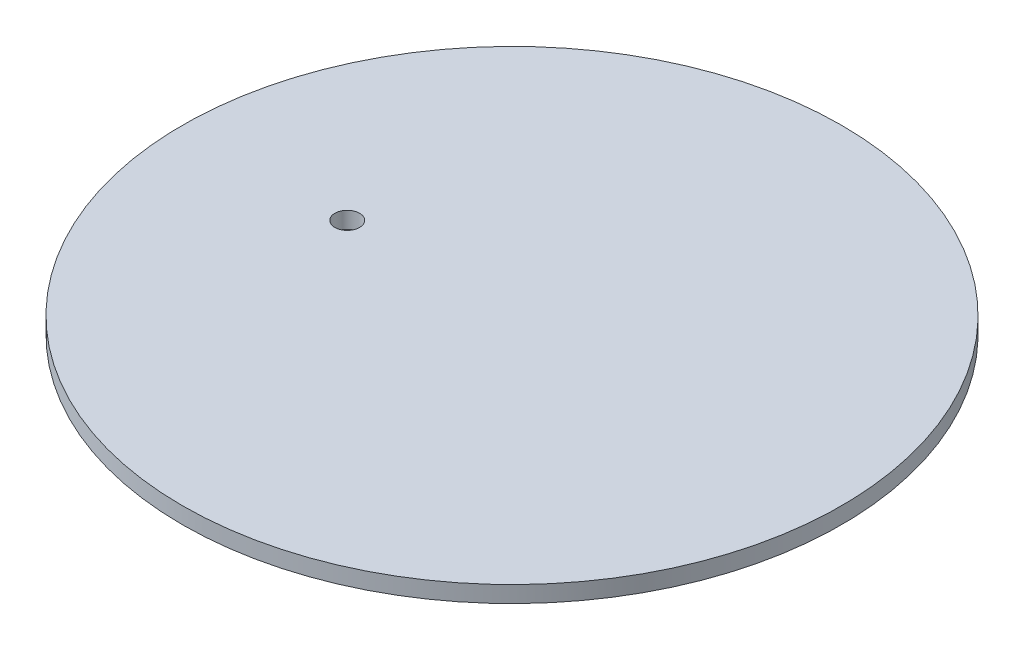
from build123d import *

# Parameters (mm, degrees)
SKETCH1_R           = 127
BOSS_EXTRUDE1_DEPTH = 6.35
SKETCH2_R           = 4.7625
CUT_EXTRUDE1_DEPTH  = 7.35


with BuildPart() as part:
    # Sketch1 → Boss-Extrude1 (new body)
    with BuildSketch(Plane(origin=(0, 0, 0), x_dir=(1, 0, 0), z_dir=(0, 1, 0))):
        Circle(SKETCH1_R)
    extrude(amount=BOSS_EXTRUDE1_DEPTH)

    # Sketch2 → Cut-Extrude1 (cut, through all)
    with BuildSketch(Plane(origin=(0, 6.35, 0), x_dir=(1, 0, 0), z_dir=(0, 1, 0))):
        with Locations((-63.5, 0)):
            Circle(SKETCH2_R)
    extrude(amount=-CUT_EXTRUDE1_DEPTH, mode=Mode.SUBTRACT)


solid = part.part
